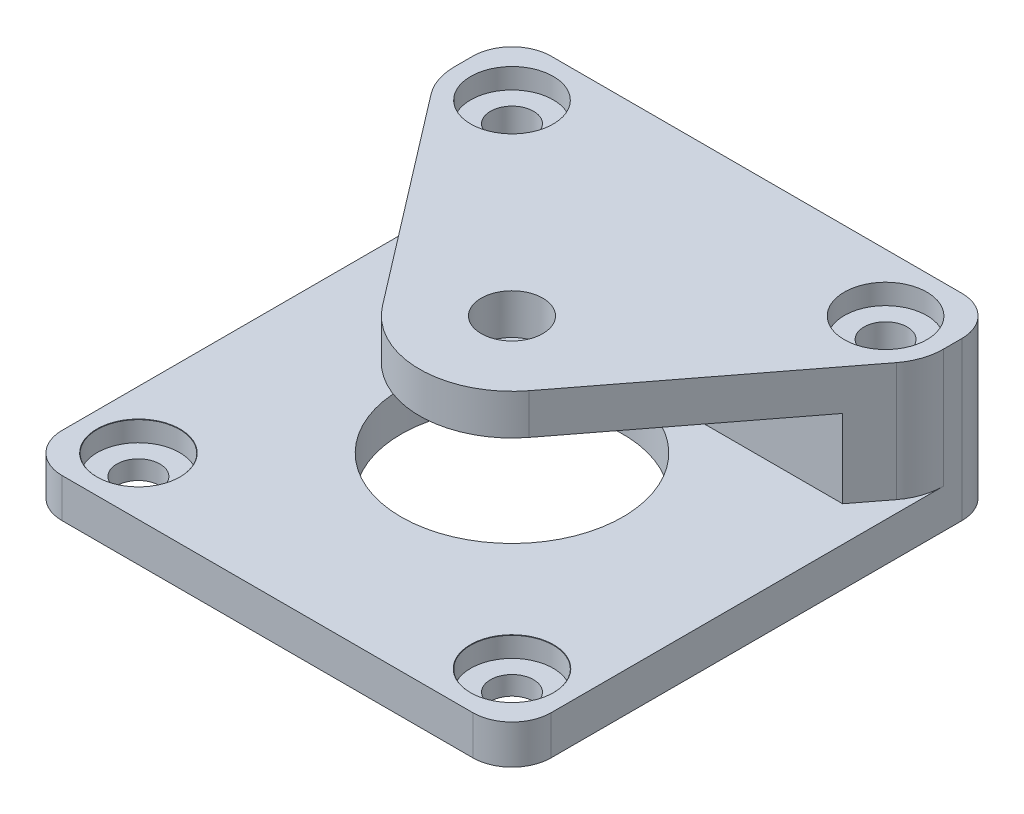
from build123d import *

# Parameters (mm, degrees)
SKETCH1_W                       = 39.69
SKETCH1_H                       = 39.69
SKETCH1_R                       = 1.75
SKETCH1_R_2                     = 9
BOSS_EXTRUDE1_DEPTH             = 3.175
SKETCH2_R                       = 1.75
BOSS_EXTRUDE2_DEPTH             = 9.635
SKETCH3_W                       = 29.69
SKETCH3_H                       = 6.35
CUT_EXTRUDE1_DEPTH              = 40.69
CBORE_FOR_M3_SBHCS1_D           = 3.4
CBORE_FOR_M3_SBHCS1_DEPTH       = 14.3
CBORE_FOR_M3_SBHCS1_CBORE_D     = 6.7
CBORE_FOR_M3_SBHCS1_CBORE_DEPTH = 1.65
CBORE_FOR_M3_SBHCS1_TIP         = 1.021463052
CBORE_FOR_M3_SBHCS2_AT_2_COUNT  = 2
CBORE_FOR_M3_SBHCS2_AT_2_PITCH  = 30.32
FILLET1_R                       = 3.175
CUT_EXTRUDE2_REACH              = 14.81
SKETCH8_R                       = 2.5


with BuildPart() as part:
    # Sketch1 → Boss-Extrude1 (new body)
    with BuildSketch(Plane(origin=(0, 0, 0), x_dir=(1, 0, 0), z_dir=(0, 1, 0))):
        with Locations((19.845, 19.845)):
            Rectangle(SKETCH1_W, SKETCH1_H)
        with Locations((4.685, 4.685)):
            Circle(SKETCH1_R, mode=Mode.SUBTRACT)
        with Locations((35.005, 4.685)):
            Circle(SKETCH1_R, mode=Mode.SUBTRACT)
        with Locations((35.005, 35.005)):
            Circle(SKETCH1_R, mode=Mode.SUBTRACT)
        with Locations((4.685, 35.005)):
            Circle(SKETCH1_R, mode=Mode.SUBTRACT)
        with Locations((19.845, 19.845)):
            Circle(SKETCH1_R_2, mode=Mode.SUBTRACT)
    extrude(amount=BOSS_EXTRUDE1_DEPTH)

    # Sketch2 → Boss-Extrude2 (add)
    with BuildSketch(Plane(origin=(0, 3.175, 0), x_dir=(1, 0, 0), z_dir=(0, 1, 0))):
        with BuildLine():
            Line((0, 35.005), (0, 39.69))
            Line((0, 39.69), (4.685, 39.69))
            Line((4.685, 39.69), (35.005, 39.69))
            Line((35.005, 39.69), (39.69, 39.69))
            Line((39.69, 39.69), (39.69, 35.005))
            ThreePointArc((39.69, 35.005), (39.441954912, 33.500787212), (38.724084904, 32.15585408))
            Line((38.724084904, 32.15585408), (25.79871116, 15.283933959))
            ThreePointArc((25.79871116, 15.283933959), (19.845, 12.345), (13.89128884, 15.283933959))
            Line((13.89128884, 15.283933959), (0.965915096, 32.15585408))
            ThreePointArc((0.965915096, 32.15585408), (0.248045088, 33.500787212), (0, 35.005))
        make_face()
        with Locations((35.005, 35.005)):
            Circle(SKETCH2_R, mode=Mode.SUBTRACT)
        with Locations((4.685, 35.005)):
            Circle(SKETCH2_R, mode=Mode.SUBTRACT)
    extrude(amount=BOSS_EXTRUDE2_DEPTH)

    # Sketch3 → Cut-Extrude1 (cut, through all)
    with BuildSketch(Plane.ZY):
        with Locations((-14.845, 6.35)):
            Rectangle(SKETCH3_W, SKETCH3_H)
    extrude(amount=-CUT_EXTRUDE1_DEPTH, mode=Mode.SUBTRACT)

    # CBORE for M3 SBHCS1
    with Locations(Plane(origin=(0, 12.81, 0), x_dir=(1, 0, 0), z_dir=(0, 1, 0))):
        with Locations((4.685, 35.005), (35.005, 35.005)):
            CounterBoreHole(CBORE_FOR_M3_SBHCS1_D / 2, CBORE_FOR_M3_SBHCS1_CBORE_D / 2, CBORE_FOR_M3_SBHCS1_CBORE_DEPTH, depth=CBORE_FOR_M3_SBHCS1_DEPTH)
            with Locations((0, 0, -(CBORE_FOR_M3_SBHCS1_DEPTH + CBORE_FOR_M3_SBHCS1_TIP / 2))):  # 118° drill point
                Cone(0, CBORE_FOR_M3_SBHCS1_D / 2, CBORE_FOR_M3_SBHCS1_TIP, mode=Mode.SUBTRACT)

    # Sketch7 → CBORE for M3 SBHCS2 (revolve, cut)
    with BuildSketch(Plane(origin=(4.685, 3.175, -4.685), x_dir=(0, 0, 1), z_dir=(1, 0, 0))):
        Polygon((0, 0), (0, 15.321463052), (1.7, 14.3), (1.7, 1.65), (3.35, 1.65), (3.35, 0.025), (3.375, 0), align=None)
    cbore_for_m3_sbhcs2 = revolve(axis=Axis((4.685, 9.525, -4.685), (0, -1, 0)), mode=Mode.SUBTRACT)

    # CBORE for M3 SBHCS2 at 2: CBORE for M3 SBHCS2 ×2
    with Locations(*[(i * CBORE_FOR_M3_SBHCS2_AT_2_PITCH, 0, 0) for i in range(1, CBORE_FOR_M3_SBHCS2_AT_2_COUNT)]):
        add(cbore_for_m3_sbhcs2, mode=Mode.SUBTRACT)

    # Fillet1
    fillet1_edges = [part.edges().sort_by_distance(p)[0] for p in [
        (0, 6.405, -39.69),
        (39.69, 6.405, -39.69),
        (39.69, 1.5875, 0),
        (0, 1.5875, 0),
    ]]
    fillet(fillet1_edges, radius=FILLET1_R)

    # Sketch8 → Cut-Extrude2 (cut, up to next)
    with BuildSketch(Plane(origin=(0, 12.81, 0), x_dir=(1, 0, 0), z_dir=(0, 1, 0)), mode=Mode.PRIVATE) as cut_extrude2_sk1:
        with Locations((19.845, 19.845)):
            Circle(SKETCH8_R)
    cut_extrude2_tool1 = extrude(cut_extrude2_sk1.sketch, amount=-CUT_EXTRUDE2_REACH, mode=Mode.PRIVATE) & part.part
    add(cut_extrude2_tool1.solids().sort_by_distance((19.845, 12.81, -19.845))[0], mode=Mode.SUBTRACT)


solid = part.part
